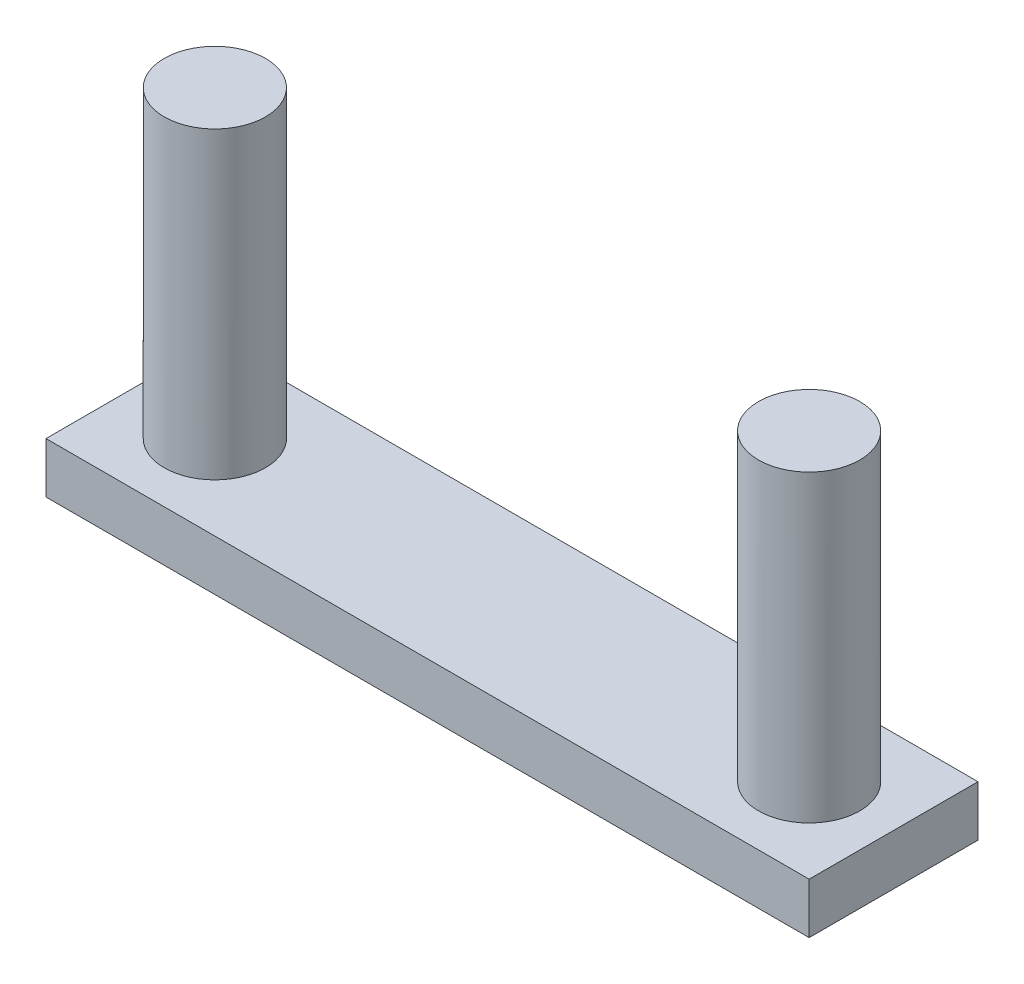
from build123d import *

# Parameters (mm, degrees)
SKETCH1_W           = 22.6
SKETCH1_H           = 5
BOSS_EXTRUDE3_DEPTH = 1.5
SKETCH3_R           = 1.5
BOSS_EXTRUDE4_DEPTH = 9


with BuildPart() as part:
    # Sketch1 → Boss-Extrude3 (new body)
    with BuildSketch(Plane(origin=(0, 0, 0), x_dir=(1, 0, 0), z_dir=(0, 1, 0))):
        with Locations((-67.186514043, -34.8441703)):
            Rectangle(SKETCH1_W, SKETCH1_H)
    extrude(amount=BOSS_EXTRUDE3_DEPTH)

    # Sketch3 → Boss-Extrude4 (add)
    with BuildSketch(Plane(origin=(0, 1.5, 0), x_dir=(1, 0, 0), z_dir=(0, 1, 0))):
        with Locations((-75.986514043, -34.8441703)):
            Circle(SKETCH3_R)
        with Locations((-58.386514043, -34.8441703)):
            Circle(SKETCH3_R)
    extrude(amount=BOSS_EXTRUDE4_DEPTH)


solid = part.part
